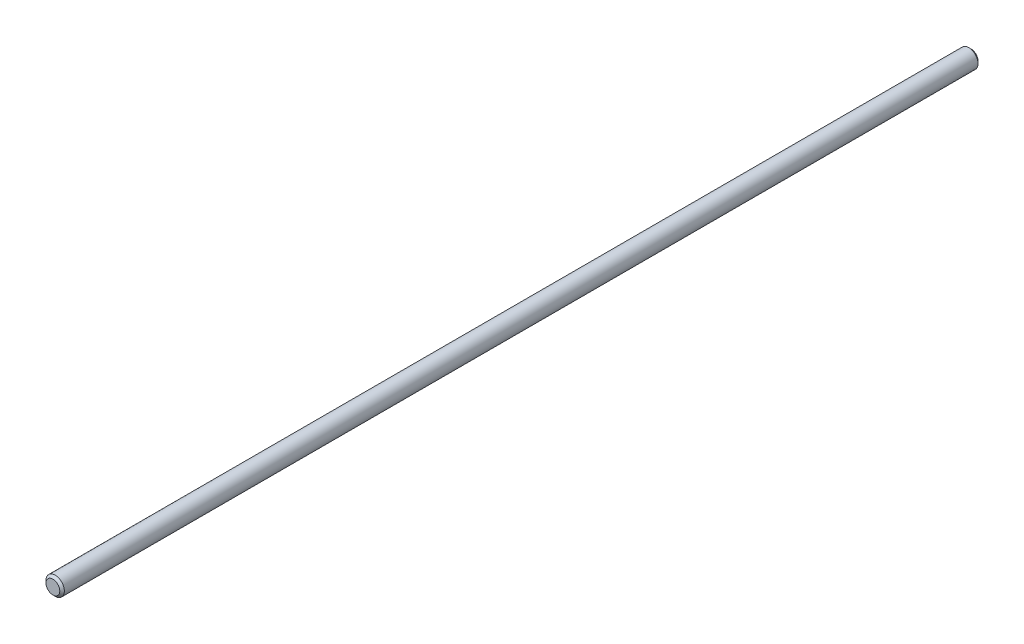
from build123d import *

# Parameters (mm, degrees)
SCHIZZO1_R                   = 4
ESTRUSIONE_ESTRUSIONE1_DEPTH = 400
SMUSSO1_SIZE                 = 1


with BuildPart() as part:
    # Schizzo1 → Estrusione-Estrusione1 (new body)
    with BuildSketch(Plane.XY):
        Circle(SCHIZZO1_R)
    extrude(amount=ESTRUSIONE_ESTRUSIONE1_DEPTH)

    # Smusso1
    smusso1_edges = [part.edges().sort_by_distance(p)[0] for p in [
        (-4, 0, 0),
        (-4, 0, 400),
    ]]
    chamfer(smusso1_edges, length=SMUSSO1_SIZE)


solid = part.part
